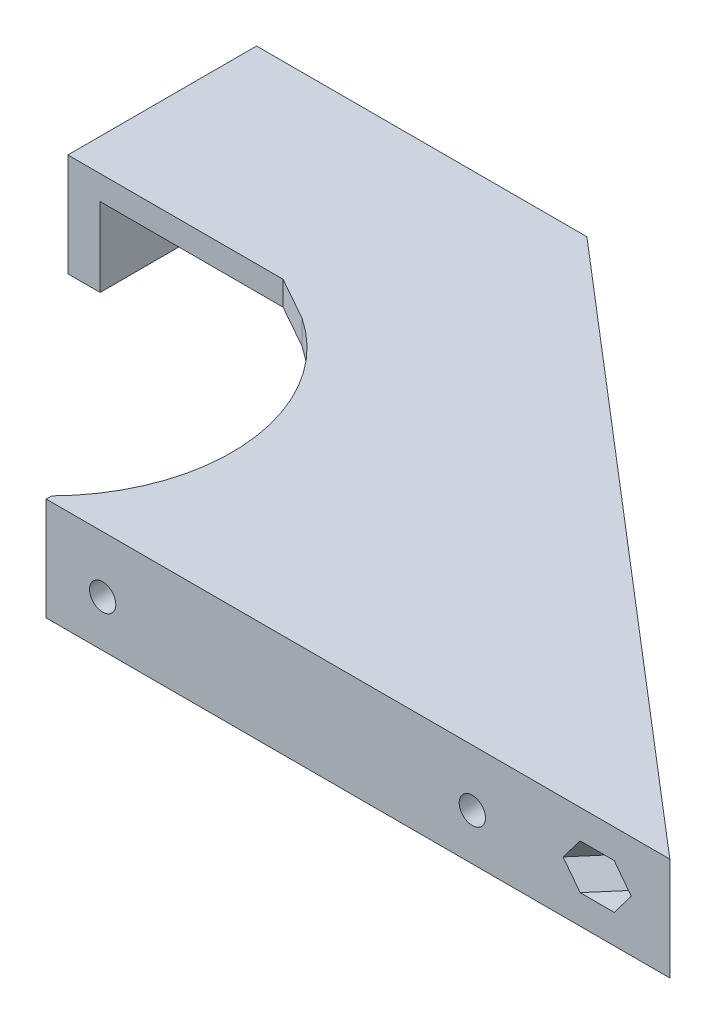
from build123d import *

# Parameters (mm, degrees)
SALIENTE_EXTRUIR1_DEPTH     = 12.75
CORTAR_EXTRUIR1_REACH       = 31.62
CROQUIS2_R                  = 1.625
CROQUIS3_R                  = 22.5
CORTAR_EXTRUIR2_DEPTH       = 13.75
SALIENTE_EXTRUIR2_DEPTH     = 3
SALIENTE_EXTRUIR3_DEPTH     = 9.75
CROQUIS6_R                  = 1.625
CORTAR_EXTRUIR3_DEPTH       = 10
CORTAR_EXTRUIR4_START       = -2
CORTAR_EXTRUIR4_DEPTH       = 10
CORTAR_EXTRUIR5_START       = -2
CORTAR_EXTRUIR5_DEPTH       = 10
CORTAR_EXTRUIR6_DEPTH       = 2
CORTAR_EXTRUIR7_REACH       = 37.25
CROQUIS10_R                 = 1.625
CORTAR_EXTRUIR8_DEPTH       = 2
CROQUIS12_W                 = 92.508691999
CROQUIS12_H                 = 24.255818813
CORTAR_EXTRUIR9_DEPTH       = 1
CORTAR_EXTRUIR9_DEPTH_BACK  = 36.25
SALIENTE_EXTRUIR4_DEPTH     = 12.75
CORTAR_EXTRUIR10_START      = -9.75
CORTAR_EXTRUIR10_DEPTH      = 9.75
CROQUIS16_W                 = 76.692813467
CROQUIS16_H                 = 12.75
CORTAR_EXTRUIR11_DEPTH      = 1
CROQUIS17_W                 = 40.657498706
CROQUIS17_H                 = 22.934549925
CORTAR_EXTRUIR12_DEPTH      = 1
CORTAR_EXTRUIR12_DEPTH_BACK = 13.75
SALIENTE_EXTRUIR5_REACH     = 14.75
CROQUIS18_W                 = 34.9120451
CROQUIS18_H                 = 3.951156815
CROQUIS20_R                 = 1.625
CORTAR_EXTRUIR14_DEPTH      = 10
CORTAR_EXTRUIR15_DEPTH      = 2
CROQUIS22_R                 = 1.625
CORTAR_EXTRUIR16_DEPTH      = 10
CORTAR_EXTRUIR17_DEPTH      = 2
SALIENTE_EXTRUIR6_DEPTH     = 12.75
CORTAR_EXTRUIR18_DEPTH      = 2
CROQUIS28_R                 = 1.625
SALIENTE_EXTRUIR7_DEPTH     = 1
CORTAR_EXTRUIR19_REACH      = 110.346
CROQUIS29_R                 = 1.993280097
CORTAR_EXTRUIR20_DEPTH      = 2
SALIENTE_EXTRUIR8_DEPTH     = 12.75
SALIENTE_EXTRUIR9_START     = -2.904645
SALIENTE_EXTRUIR9_DEPTH     = 5
SALIENTE_EXTRUIR10_REACH    = 76.413
CORTAR_EXTRUIR21_START      = -9.75
CORTAR_EXTRUIR21_DEPTH      = 9.75
CROQUIS36_R                 = 1.625
CORTAR_EXTRUIR22_DEPTH      = 15
CORTAR_EXTRUIR23_DEPTH      = 2
CORTAR_EXTRUIR24_START      = -2
CORTAR_EXTRUIR24_DEPTH      = 73.413335578
CROQUIS19_W                 = 120.448667976
CROQUIS19_H                 = 32.886651308
CORTAR_EXTRUIR13_DEPTH      = 1
CORTAR_EXTRUIR13_DEPTH_BACK = 62.623336743
CORTAR_EXTRUIR25_DEPTH      = 1
CORTAR_EXTRUIR25_DEPTH_BACK = 13.75
CROQUIS42_R                 = 1.625
SALIENTE_EXTRUIR11_DEPTH    = 1


with BuildPart() as part:
    # Croquis1 → Saliente-Extruir1 (new body)
    with BuildSketch(Plane(origin=(0, 0, 0), x_dir=(1, 0, 0), z_dir=(0, 1, 0))):
        Polygon((0, 0), (72.78319995, 0), (38.224450787, 29.62043043), (35.621353918, 26.5833452), (60.803074847, 5), (0, 5), align=None)
    extrude(amount=SALIENTE_EXTRUIR1_DEPTH)

    # Croquis2 → Cortar-Extruir1 (cut, up to next)
    with BuildSketch(Plane.XY, mode=Mode.PRIVATE) as cortar_extruir1_sk1:
        with Locations((52.78319995, 5.75)):
            Circle(CROQUIS2_R)
    cortar_extruir1_tool1 = extrude(cortar_extruir1_sk1.sketch, amount=-CORTAR_EXTRUIR1_REACH, mode=Mode.PRIVATE) & part.part
    add(cortar_extruir1_tool1.solids().sort_by_distance((52.7832, 5.75, 0))[0], mode=Mode.SUBTRACT)
    # Croquis2 → Cortar-Extruir1 (cut, up to next)
    with BuildSketch(Plane.XY, mode=Mode.PRIVATE) as cortar_extruir1_sk2:
        with Locations((6.99999995, 5.75)):
            Circle(CROQUIS2_R)
    cortar_extruir1_tool2 = extrude(cortar_extruir1_sk2.sketch, amount=-CORTAR_EXTRUIR1_REACH, mode=Mode.PRIVATE) & part.part
    add(cortar_extruir1_tool2.solids().sort_by_distance((7, 5.75, 0))[0], mode=Mode.SUBTRACT)

    # Croquis3 → Cortar-Extruir2 (cut, through all)
    with BuildSketch(Plane(origin=(0, 12.75, 0), x_dir=(1, 0, 0), z_dir=(0, 1, 0))):
        with Locations((-16, 16.5)):
            Circle(CROQUIS3_R)
    extrude(amount=-CORTAR_EXTRUIR2_DEPTH, mode=Mode.SUBTRACT)

    # Croquis4 → Saliente-Extruir2 (add)
    with BuildSketch(Plane(origin=(0, 12.75, 0), x_dir=(1, 0, 0), z_dir=(0, 1, 0))):
        with BuildLine():
            Line((38.224450787, 29.62043043), (31.656319269, 35.25))
            Line((31.656319269, 35.25), (-3.562657036, 35.25))
            ThreePointArc((-3.562657036, 35.25), (5.936291456, 21.504909307), (3.339079606, 5))
            Line((3.339079606, 5), (60.803074847, 5))
            Line((60.803074847, 5), (35.621353918, 26.5833452))
            Line((35.621353918, 26.5833452), (38.224450787, 29.62043043))
        make_face()
    extrude(amount=-SALIENTE_EXTRUIR2_DEPTH)

    # Croquis5 → Saliente-Extruir3 (add)
    with BuildSketch(Plane.XZ.offset(-9.75)):
        with BuildLine():
            Line((-3.562657036, -35.25), (31.656319269, -35.25))
            Line((31.656319269, -35.25), (38.224450787, -29.62043043))
            Line((38.224450787, -29.62043043), (35.621353918, -26.5833452))
            Line((35.621353918, -26.5833452), (30.17667434, -31.25))
            Line((30.17667434, -31.25), (0.990806338, -31.25))
            ThreePointArc((0.990806338, -31.25), (-1.15062315, -33.404023402), (-3.562657036, -35.25))
        make_face()
    extrude(amount=SALIENTE_EXTRUIR3_DEPTH)

    # Croquis6 → Cortar-Extruir3 (cut)
    with BuildSketch(Plane(origin=(30.824200619, 0, -35.963211942), x_dir=(-0.759271307, 0, -0.650774217), z_dir=(0.650774217, 0, -0.759271307))):
        with Locations((-47.262195378, 6.375)):
            Circle(CROQUIS6_R)
        with Locations((-16.095943758, 6.375)):
            Circle(CROQUIS6_R)
    extrude(amount=-CORTAR_EXTRUIR3_DEPTH, mode=Mode.SUBTRACT)

    # Croquis7 → Cortar-Extruir4 (cut)
    with BuildSketch(Plane(origin=(28.22110375, 0, -32.926126712), x_dir=(0.759271307, 0, 0.650774217), z_dir=(-0.650774217, 0, 0.759271307)).offset(CORTAR_EXTRUIR4_START)):
        Polygon((48.849908618, 3.625), (50.437621859, 6.375), (48.849908618, 9.125), (45.674482138, 9.125), (44.086768898, 6.375), (45.674482138, 3.625), align=None)
    extrude(amount=CORTAR_EXTRUIR4_DEPTH, mode=Mode.SUBTRACT)

    # Croquis8 → Cortar-Extruir5 (cut)
    with BuildSketch(Plane(origin=(28.22110375, 0, -32.926126712), x_dir=(0.759271307, 0, 0.650774217), z_dir=(-0.650774217, 0, 0.759271307)).offset(CORTAR_EXTRUIR5_START)):
        Polygon((17.683656999, 3.625), (19.271370239, 6.375), (17.683656999, 9.125), (14.508230518, 9.125), (12.920517278, 6.375), (14.508230518, 3.625), align=None)
    extrude(amount=CORTAR_EXTRUIR5_DEPTH, mode=Mode.SUBTRACT)

    # Croquis9 → Cortar-Extruir6 (cut)
    with BuildSketch(Plane(origin=(0, 0, -5), x_dir=(-1, 0, 0), z_dir=(0, 0, -1))):
        Polygon((-5.41228671, 3), (-3.824573469, 5.75), (-5.41228671, 8.5), (-8.58771319, 8.5), (-10.175426431, 5.75), (-8.58771319, 3), align=None)
        Polygon((-51.19548671, 3), (-49.607773469, 5.75), (-51.19548671, 8.5), (-54.37091319, 8.5), (-55.958626431, 5.75), (-54.37091319, 3), align=None)
    extrude(amount=-CORTAR_EXTRUIR6_DEPTH, mode=Mode.SUBTRACT)

    # Croquis10 → Cortar-Extruir7 (cut, up to next)
    with BuildSketch(Plane(origin=(0, 0, -35.25), x_dir=(-1, 0, 0), z_dir=(0, 0, -1)), mode=Mode.PRIVATE) as cortar_extruir7_sk1:
        with Locations((-21.656319269, 6.375)):
            Circle(CROQUIS10_R)
    cortar_extruir7_tool1 = extrude(cortar_extruir7_sk1.sketch, amount=-CORTAR_EXTRUIR7_REACH, mode=Mode.PRIVATE) & part.part
    add(cortar_extruir7_tool1.solids().sort_by_distance((21.656319, 6.375, -35.25))[0], mode=Mode.SUBTRACT)

    # Croquis11 → Cortar-Extruir8 (cut)
    with BuildSketch(Plane.XY.offset(-31.25)):
        Polygon((23.24403251, 3.625), (24.83174575, 6.375), (23.24403251, 9.125), (20.068606029, 9.125), (18.480892789, 6.375), (20.068606029, 3.625), align=None)
    extrude(amount=-CORTAR_EXTRUIR8_DEPTH, mode=Mode.SUBTRACT)

    # Simetría1: part across plane


with BuildPart() as part_1:
    add(part.part)
    add(part.part.mirror(Plane.ZX))

    # Croquis12 → Cortar-Extruir9 (cut, two sides)
    with BuildSketch(Plane(origin=(0, 0, -35.25), x_dir=(-1, 0, 0), z_dir=(0, 0, -1))) as cortar_extruir9_sk:
        with Locations((-33.077560565, 12.127909407)):
            Rectangle(CROQUIS12_W, CROQUIS12_H)
    extrude(amount=CORTAR_EXTRUIR9_DEPTH, mode=Mode.SUBTRACT)
    extrude(cortar_extruir9_sk.sketch, amount=-CORTAR_EXTRUIR9_DEPTH_BACK, mode=Mode.SUBTRACT)

    # Croquis13 → Saliente-Extruir4 (add)
    with BuildSketch(Plane.XZ.offset(12.75)):
        Polygon((-35.562657036, -82.38260805), (-35.562657036, -38.25), (-8.913300435, -38.25), (-3.562657036, -35.25), (31.656319269, -35.25), (0.000162281, -62.38260805), align=None)
    extrude(amount=-SALIENTE_EXTRUIR4_DEPTH)

    # Croquis14 → Cortar-Extruir10 (cut)
    with BuildSketch(Plane(origin=(0, 0, 0), x_dir=(1, 0, 0), z_dir=(0, 1, 0)).offset(CORTAR_EXTRUIR10_START)):
        Polygon((30.17667434, 31.25), (0.990806338, 31.25), (-31.562657036, 38.25), (-31.562657036, 75.543902968), (-2.303881466, 59.089203295), align=None)
    extrude(amount=CORTAR_EXTRUIR10_DEPTH, mode=Mode.SUBTRACT)

    # Croquis16 → Cortar-Extruir11 (cut)
    with BuildSketch(Plane(origin=(30.824200619, 0, -35.963211942), x_dir=(-0.759271307, 0, -0.650774217), z_dir=(0.650774217, 0, -0.759271307))):
        with Locations((2.250462975, -6.375)):
            Rectangle(CROQUIS16_W, CROQUIS16_H)
    extrude(amount=-CORTAR_EXTRUIR11_DEPTH, mode=Mode.SUBTRACT)

    # Croquis17 → Cortar-Extruir12 (cut, two sides)
    with BuildSketch(Plane.XZ.offset(12.75)) as cortar_extruir12_sk:
        with Locations((-20.328587072, -73.090611706)):
            Rectangle(CROQUIS17_W, CROQUIS17_H)
    extrude(amount=CORTAR_EXTRUIR12_DEPTH, mode=Mode.SUBTRACT)
    extrude(cortar_extruir12_sk.sketch, amount=-CORTAR_EXTRUIR12_DEPTH_BACK, mode=Mode.SUBTRACT)

    # Croquis18 → Saliente-Extruir5 (add, up to next)
    with BuildSketch(Plane(origin=(0, 0, 0), x_dir=(1, 0, 0), z_dir=(0, 1, 0)), mode=Mode.PRIVATE) as saliente_extruir5_sk1:
        with Locations((-18.106634486, 59.647758336)):
            Rectangle(CROQUIS18_W, CROQUIS18_H)
    saliente_extruir5_tool1 = extrude(saliente_extruir5_sk1.sketch, amount=-SALIENTE_EXTRUIR5_REACH, mode=Mode.PRIVATE) - part_1.part
    add(saliente_extruir5_tool1.solids().sort_by_distance((-18.106634, 0, -59.647758))[0])

    # Croquis20 → Cortar-Extruir14 (cut)
    with BuildSketch(Plane(origin=(30.173426402, 0, -35.203940634), x_dir=(-0.759271307, 0, -0.650774217), z_dir=(0.650774217, 0, -0.759271307))):
        with Locations((25.596869709, -6.375)):
            Circle(CROQUIS20_R)
        with Locations((-16.095943758, -6.375)):
            Circle(CROQUIS20_R)
    extrude(amount=-CORTAR_EXTRUIR14_DEPTH, mode=Mode.SUBTRACT)

    # Croquis21 → Cortar-Extruir15 (cut)
    with BuildSketch(Plane(origin=(28.22110375, 0, -32.926126712), x_dir=(0.759271307, 0, 0.650774217), z_dir=(-0.650774217, 0, 0.759271307))):
        Polygon((-24.009156469, -9.125), (-22.421443229, -6.375), (-24.009156469, -3.625), (-27.184582949, -3.625), (-28.77229619, -6.375), (-27.184582949, -9.125), align=None)
    extrude(amount=-CORTAR_EXTRUIR15_DEPTH, mode=Mode.SUBTRACT)

    # Croquis22 → Cortar-Extruir16 (cut)
    with BuildSketch(Plane(origin=(0, 0, -61.623336743), x_dir=(-1, 0, 0), z_dir=(0, 0, -1))):
        with Locations((18.112657036, -6.375)):
            Circle(CROQUIS22_R)
    extrude(amount=-CORTAR_EXTRUIR16_DEPTH, mode=Mode.SUBTRACT)

    # Croquis23 → Cortar-Extruir17 (cut)
    with BuildSketch(Plane.XY.offset(-57.672179928)):
        Polygon((-16.524943796, -9.125), (-14.937230556, -6.375), (-16.524943796, -3.625), (-19.700370276, -3.625), (-21.288083517, -6.375), (-19.700370276, -9.125), align=None)
    extrude(amount=-CORTAR_EXTRUIR17_DEPTH, mode=Mode.SUBTRACT)

    # Croquis26 → Saliente-Extruir6 (add)
    with BuildSketch(Plane(origin=(0, 0, 0), x_dir=(1, 0, 0), z_dir=(0, 1, 0))):
        Polygon((60.803074847, 5), (-2.287792345, 59.07541325), (-2.938566562, 58.316141943), (60.15230063, 4.240728693), align=None)
    extrude(amount=-SALIENTE_EXTRUIR6_DEPTH)

    # Croquis27 → Cortar-Extruir18 (cut)
    with BuildSketch(Plane(origin=(27.570329533, 0, -32.166855405), x_dir=(0.759271307, 0, 0.650774217), z_dir=(-0.650774217, 0, 0.759271307))):
        Polygon((-22.421443229, -6.375), (-24.009156469, -3.625), (-27.184582949, -3.625), (-28.77229619, -6.375), (-27.184582949, -9.125), (-24.009156469, -9.125), align=None)
        Polygon((19.271370239, -6.375), (17.683656999, -3.625), (14.508230518, -3.625), (12.920517278, -6.375), (14.508230518, -9.125), (17.683656999, -9.125), align=None)
    extrude(amount=-CORTAR_EXTRUIR18_DEPTH, mode=Mode.SUBTRACT)

    # Croquis28 → Saliente-Extruir7 (add)
    with BuildSketch(Plane(origin=(29.522652185, 0, -34.444669327), x_dir=(0.759271307, 0, 0.650774217), z_dir=(-0.650774217, 0, 0.759271307))):
        Polygon((-24.009156469, -3.625), (-27.184582949, -3.625), (-28.77229619, -6.375), (-27.184582949, -9.125), (-24.009156469, -9.125), (-22.421443229, -6.375), align=None)
        with Locations((-25.596869709, -6.375)):
            Circle(CROQUIS28_R, mode=Mode.SUBTRACT)
        Polygon((17.683656999, -3.625), (14.508230518, -3.625), (12.920517278, -6.375), (14.508230518, -9.125), (17.683656999, -9.125), (19.271370239, -6.375), align=None)
        with Locations((16.095943758, -6.375)):
            Circle(CROQUIS28_R, mode=Mode.SUBTRACT)
    extrude(amount=SALIENTE_EXTRUIR7_DEPTH)

    # Croquis29 → Cortar-Extruir19 (cut, up to next)
    with BuildSketch(Plane.ZY.offset(35.562657036), mode=Mode.PRIVATE) as cortar_extruir19_sk1:
        with Locations((-51.623336743, -6.375)):
            Circle(CROQUIS29_R)
    cortar_extruir19_tool1 = extrude(cortar_extruir19_sk1.sketch, amount=-CORTAR_EXTRUIR19_REACH, mode=Mode.PRIVATE) & part_1.part
    add(cortar_extruir19_tool1.solids().sort_by_distance((-35.562657, -6.375, -51.623337))[0], mode=Mode.SUBTRACT)

    # Croquis30 → Cortar-Extruir20 (cut)
    with BuildSketch(Plane(origin=(-31.562657036, 0, 0), x_dir=(0, 0, -1), z_dir=(1, 0, 0))):
        Polygon((53.238108484, -9.125), (54.825821725, -6.375), (53.238108484, -3.625), (50.062682004, -3.625), (48.474968763, -6.375), (50.062682004, -9.125), align=None)
    extrude(amount=-CORTAR_EXTRUIR20_DEPTH, mode=Mode.SUBTRACT)

    # Croquis32 → Saliente-Extruir8 (add)
    with BuildSketch(Plane.XZ.offset(12.75)):
        Polygon((-0.650611936, -61.623336743), (5.349388064, -61.623336743), (60.1210833, -14.678316233), (60.771857517, -15.43758754), (78.78319995, 0), (72.78319995, 0), (58.230815026, -12.472902396), (57.580040809, -11.713631088), align=None)
    extrude(amount=-SALIENTE_EXTRUIR8_DEPTH)

    # Croquis33 → Saliente-Extruir9 (add)
    with BuildSketch(Plane(origin=(32.714468893, 0, -38.168625779), x_dir=(-0.759271307, 0, -0.650774217), z_dir=(0.650774217, 0, -0.759271307)).offset(SALIENTE_EXTRUIR9_START)):
        Polygon((-14.508230518, -3.625), (-17.683656999, -3.625), (-19.271370239, -6.375), (-17.683656999, -9.125), (-14.508230518, -9.125), (-12.920517278, -6.375), align=None)
        Polygon((27.184582949, -3.625), (24.009156469, -3.625), (22.421443229, -6.375), (24.009156469, -9.125), (27.184582949, -9.125), (28.77229619, -6.375), align=None)
    extrude(amount=-SALIENTE_EXTRUIR9_DEPTH)

    # Saliente-Extruir10: up to this face of the body (flat: up to its plane)
    saliente_extruir10_end = Plane(part_1.part.faces().sort_by_distance((38.729797406, -6.385876659, 0))[0])
    # Croquis34 → Saliente-Extruir10 (add, up to the picked face)
    with BuildSketch(Plane(origin=(33.36524311, 0, -38.927897086), x_dir=(-0.759271307, 0, -0.650774217), z_dir=(0.650774217, 0, -0.759271307)), mode=Mode.PRIVATE) as saliente_extruir10_sk1:
        Polygon((-45.674482138, -3.625), (-48.849908618, -3.625), (-50.437621859, -6.375), (-48.849908618, -9.125), (-45.674482138, -9.125), (-44.086768898, -6.375), align=None)
    saliente_extruir10_tool1 = split(extrude(saliente_extruir10_sk1.sketch, amount=-SALIENTE_EXTRUIR10_REACH, mode=Mode.PRIVATE), bisect_by=saliente_extruir10_end, keep=Keep.BOTH, mode=Mode.PRIVATE)
    add(saliente_extruir10_tool1.solids().sort_by_distance((69.250072, -6.375, -8.170879))[0])

    # Croquis35 → Cortar-Extruir21 (cut)
    with BuildSketch(Plane(origin=(0, 0, 0), x_dir=(1, 0, 0), z_dir=(0, 1, 0)).offset(CORTAR_EXTRUIR21_START)):
        Polygon((-2.187243188, 57.672179928), (3.812756812, 57.672179928), (65.266443595, 5), (59.266443595, 5), align=None)
    extrude(amount=CORTAR_EXTRUIR21_DEPTH, mode=Mode.SUBTRACT)

    # Croquis36 → Cortar-Extruir22 (cut)
    with BuildSketch(Plane(origin=(33.36524311, 0, -38.927897086), x_dir=(-0.759271307, 0, -0.650774217), z_dir=(0.650774217, 0, -0.759271307))):
        with Locations((-51.817823222, -6.375)):
            Circle(CROQUIS36_R)
        with Locations((-20.647823222, -6.375)):
            Circle(CROQUIS36_R)
        with Locations((21.042176778, -6.375)):
            Circle(CROQUIS36_R)
    extrude(amount=-CORTAR_EXTRUIR22_DEPTH, mode=Mode.SUBTRACT)

    # Croquis38 → Cortar-Extruir23 (cut)
    with BuildSketch(Plane(origin=(30.111372024, 0, -35.131540549), x_dir=(0.759271307, 0, 0.650774217), z_dir=(-0.650774217, 0, 0.759271307))):
        Polygon((-19.440029781, -9.15), (-17.837882784, -6.375), (-19.440029781, -3.6), (-22.644323775, -3.6), (-24.246470772, -6.375), (-22.644323775, -9.15), align=None)
        Polygon((22.249970219, -9.15), (23.852117216, -6.375), (22.249970219, -3.6), (19.045676225, -3.6), (17.443529228, -6.375), (19.045676225, -9.15), align=None)
    extrude(amount=-CORTAR_EXTRUIR23_DEPTH, mode=Mode.SUBTRACT)

    # Croquis39 → Cortar-Extruir24 (cut, through all)
    with BuildSketch(Plane(origin=(33.36524311, 0, -38.927897086), x_dir=(-0.759271307, 0, -0.650774217), z_dir=(0.650774217, 0, -0.759271307)).offset(CORTAR_EXTRUIR24_START)):
        Polygon((-50.215676225, -9.15), (-48.613529228, -6.375), (-50.215676225, -3.6), (-53.419970219, -3.6), (-55.022117216, -6.375), (-53.419970219, -9.15), align=None)
    extrude(amount=-CORTAR_EXTRUIR24_DEPTH, mode=Mode.SUBTRACT)

    # Simetría2: part across face


with BuildPart() as part_2:
    add(part_1.part)
    add(part_1.part.mirror(Plane(origin=(15.909867024, -12.75, -29.216307939), x_dir=(0, 0, 1), z_dir=(0, -1, 0))))

    # Croquis19 → Cortar-Extruir13 (cut, two sides)
    with BuildSketch(Plane(origin=(0, 0, -61.623336743), x_dir=(-1, 0, 0), z_dir=(0, 0, -1))) as cortar_extruir13_sk:
        with Locations((-18.558865962, 3.693325654)):
            Rectangle(CROQUIS19_W, CROQUIS19_H)
    extrude(amount=CORTAR_EXTRUIR13_DEPTH, mode=Mode.SUBTRACT)
    extrude(cortar_extruir13_sk.sketch, amount=-CORTAR_EXTRUIR13_DEPTH_BACK, mode=Mode.SUBTRACT)

    # Croquis40 → Cortar-Extruir25 (cut, two sides)
    with BuildSketch(Plane.XZ.offset(25.5)) as cortar_extruir25_sk:
        Polygon((60.1210833, -14.678316233), (60.771857517, -15.43758754), (81.920264416, 2.688789439), (81.269490199, 3.448060746), align=None)
    extrude(amount=CORTAR_EXTRUIR25_DEPTH, mode=Mode.SUBTRACT)
    extrude(cortar_extruir25_sk.sketch, amount=-CORTAR_EXTRUIR25_DEPTH_BACK, mode=Mode.SUBTRACT)

    # Croquis42 → Saliente-Extruir11 (add)
    with BuildSketch(Plane(origin=(32.063694676, 0, -37.409354471), x_dir=(0.759271307, 0, 0.650774217), z_dir=(-0.650774217, 0, 0.759271307))):
        Polygon((53.419970219, -16.35), (50.215676225, -16.35), (48.613529228, -19.125), (50.215676225, -21.9), (53.419970219, -21.9), (55.022117216, -19.125), align=None)
        with Locations((51.817823222, -19.125)):
            Circle(CROQUIS42_R, mode=Mode.SUBTRACT)
    extrude(amount=SALIENTE_EXTRUIR11_DEPTH)


solid = part_2.part
